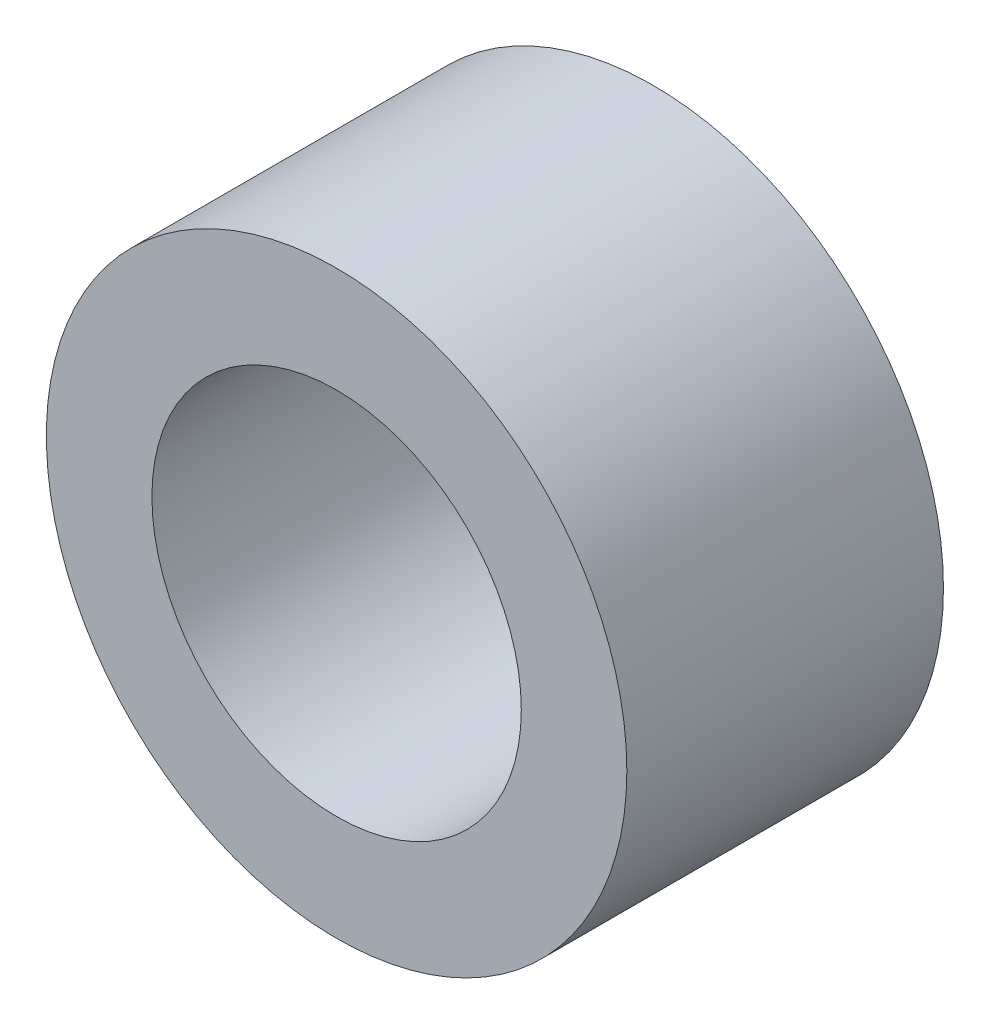
from build123d import *

# Parameters (mm, degrees)
SKETCH3_R           = 17.4625
SKETCH3_R_2         = 11.1125
BOSS_EXTRUDE1_DEPTH = 9.525


with BuildPart() as part:
    # Sketch3 → Boss-Extrude1 (new body, symmetric)
    with BuildSketch(Plane.XY):
        Circle(SKETCH3_R)
        Circle(SKETCH3_R_2, mode=Mode.SUBTRACT)
    extrude(amount=BOSS_EXTRUDE1_DEPTH, both=True)


solid = part.part
